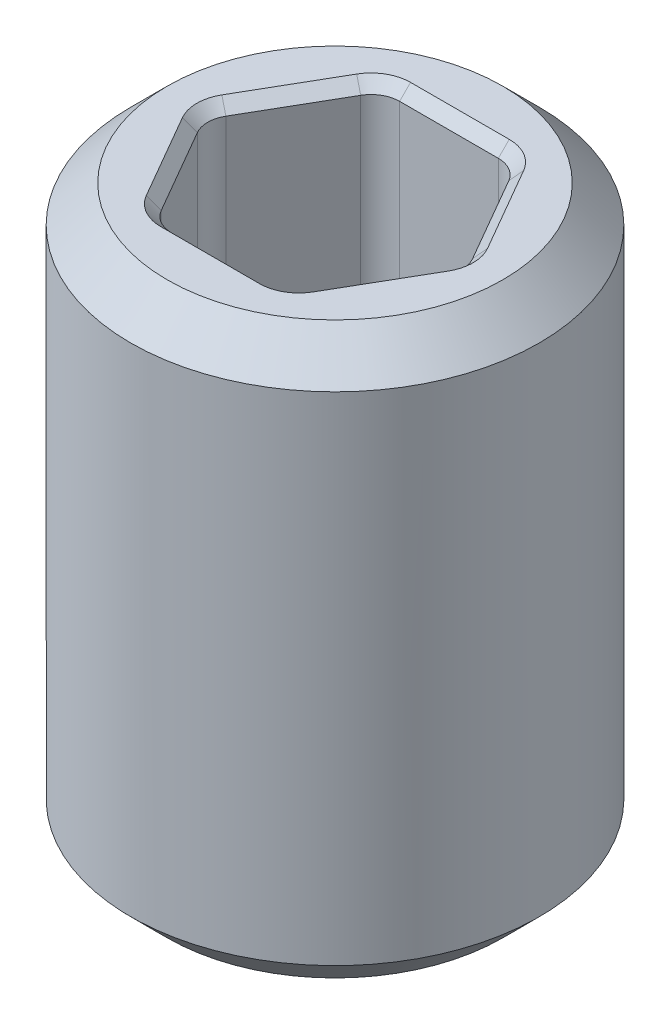
from build123d import *

# Parameters (mm, degrees)
SKETCH1_W               = 1.4224
SKETCH1_H               = 3.96875
CUT_EXTRUDE1_DEPTH      = 2.984375
CUT_EXTRUDE1_DEPTH_BACK = 2.984375
FILLET1_R               = 0.1984375
CHAMFER1_SIZE           = 0.254
CHAMFER2_SIZE           = 0.0762


with BuildPart() as part:
    # Sketch1 → Revolve1 (revolve)
    with BuildSketch(Plane.XY):
        with Locations((0.7112, 0)):
            Rectangle(SKETCH1_W, SKETCH1_H)
    revolve(axis=Axis((0, -1.704166029, 0), (0, 1, 0)))

    # Sketch3 → Cut-Extrude1 (cut, two sides)
    with BuildSketch(Plane(origin=(0, 0, 0), x_dir=(1, 0, 0), z_dir=(0, 1, 0))) as cut_extrude1_sk:
        Polygon((0.916543552, 0), (0.458271776, 0.79375), (-0.458271776, 0.79375), (-0.916543552, 0), (-0.458271776, -0.79375), (0.458271776, -0.79375), align=None)
    extrude(amount=CUT_EXTRUDE1_DEPTH, mode=Mode.SUBTRACT)
    extrude(cut_extrude1_sk.sketch, amount=-CUT_EXTRUDE1_DEPTH_BACK, mode=Mode.SUBTRACT)

    # Fillet1
    fillet1_edges = [part.edges().sort_by_distance(p)[0] for p in [
        (0.458271776, 0, -0.79375),
        (0.916543552, 0, 0),
        (0.458271776, 0, 0.79375),
        (-0.458271776, 0, 0.79375),
        (-0.916543552, 0, 0),
        (-0.458271776, 0, -0.79375),
    ]]
    fillet(fillet1_edges, radius=FILLET1_R)

    # Chamfer1
    chamfer1_edges = [part.edges().sort_by_distance(p)[0] for p in [
        (-1.4224, 1.984375, 0),
        (-1.4224, -1.984375, 0),
    ]]
    chamfer(chamfer1_edges, length=CHAMFER1_SIZE)

    # Chamfer2
    chamfer2_edges = [part.edges().sort_by_distance(p)[0] for p in [
        (0.687407664, -1.984375, -0.396875),
        (0.687407664, 1.984375, -0.396875),
        (0.687407664, -1.984375, 0.396875),
        (0.687407664, 1.984375, 0.396875),
        (0, -1.984375, 0.79375),
        (0, 1.984375, 0.79375),
        (-0.687407664, -1.984375, 0.396875),
        (-0.687407664, 1.984375, 0.396875),
        (-0.687407664, -1.984375, -0.396875),
        (-0.687407664, 1.984375, -0.396875),
        (0, -1.984375, -0.79375),
        (0, 1.984375, -0.79375),
        (0.885845164, 1.984375, 0),
        (0.885845164, -1.984375, 0),
        (0.442922582, 1.984375, 0.767164416),
        (0.442922582, -1.984375, 0.767164416),
        (-0.442922582, 1.984375, 0.767164416),
        (-0.442922582, -1.984375, 0.767164416),
        (-0.885845164, 1.984375, 0),
        (-0.885845164, -1.984375, 0),
        (-0.442922582, 1.984375, -0.767164416),
        (-0.442922582, -1.984375, -0.767164416),
        (0.442922582, 1.984375, -0.767164416),
        (0.442922582, -1.984375, -0.767164416),
    ]]
    chamfer(chamfer2_edges, length=CHAMFER2_SIZE)


solid = part.part
